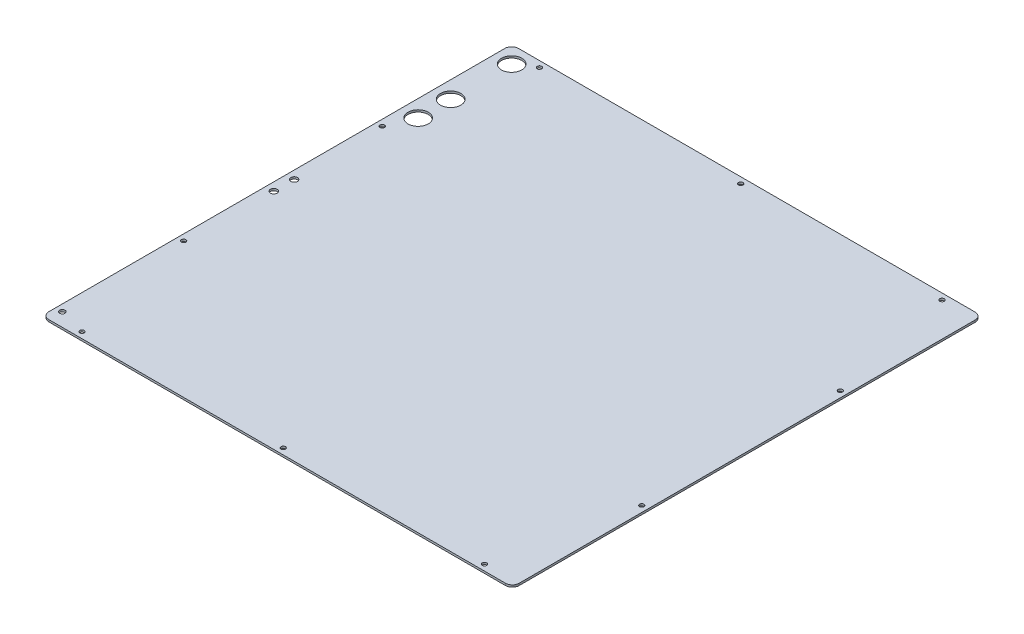
from build123d import *

# Parameters (mm, degrees)
SKETCH1_W            = 694
SKETCH1_H            = 693
BOSS_EXTRUDE1_DEPTH  = 3
M6_CLEARANCE_HOLE1_D = 6.6
LPATTERN1_COUNT      = 3
LPATTERN1_PITCH      = 297
MIRROR1_COPY_1_D     = 6.6
MIRROR1_COPY_2_D     = 6.6
M6_CLEARANCE_HOLE2_D = 6.6
LPATTERN2_COUNT      = 2
LPATTERN2_PITCH      = 293
MIRROR2_COPY_1_D     = 6.6
FILLET1_R            = 10
SKETCH6_R            = 4
SKETCH6_R_2          = 5
SKETCH6_R_3          = 15
CUT_EXTRUDE1_DEPTH   = 4


with BuildPart() as part:
    # Sketch1 → Boss-Extrude1 (new body)
    with BuildSketch(Plane(origin=(0, 0, 0), x_dir=(1, 0, 0), z_dir=(0, 1, 0))):
        Rectangle(SKETCH1_W, SKETCH1_H)
    extrude(amount=BOSS_EXTRUDE1_DEPTH)

    # M6 Clearance Hole1 (through all)
    with Locations(Plane(origin=(0, 3, 0), x_dir=(1, 0, 0), z_dir=(0, 1, 0))):
        with Locations((297, -337.5)):
            m6_clearance_hole1 = Hole(M6_CLEARANCE_HOLE1_D / 2)

    # LPattern1: M6 Clearance Hole1 ×3
    with Locations(*[(-i * LPATTERN1_PITCH, 0, 0) for i in range(1, LPATTERN1_COUNT)]):
        add(m6_clearance_hole1, mode=Mode.SUBTRACT)

    # Mirror1: M6 Clearance Hole1 across plane
    add(m6_clearance_hole1.mirror(Plane.XY), mode=Mode.SUBTRACT)

    # Mirror1 copy 1 (through all)
    with Locations(Plane(origin=(-297, 3, 0), x_dir=(1, 0, 0), z_dir=(0, 1, 0))):
        with Locations((297, 337.5)):
            Hole(MIRROR1_COPY_1_D / 2)

    # Mirror1 copy 2 (through all)
    with Locations(Plane(origin=(-594, 3, 0), x_dir=(1, 0, 0), z_dir=(0, 1, 0))):
        with Locations((297, 337.5)):
            Hole(MIRROR1_COPY_2_D / 2)

    # M6 Clearance Hole2 (through all)
    with Locations(Plane(origin=(0, 3, 0), x_dir=(1, 0, 0), z_dir=(0, 1, 0))):
        with Locations((338, -146.5)):
            m6_clearance_hole2 = Hole(M6_CLEARANCE_HOLE2_D / 2)

    # LPattern2: M6 Clearance Hole2 ×2
    with Locations(*[(0, 0, -i * LPATTERN2_PITCH) for i in range(1, LPATTERN2_COUNT)]):
        add(m6_clearance_hole2, mode=Mode.SUBTRACT)

    # Mirror2: M6 Clearance Hole2 across plane
    add(m6_clearance_hole2.mirror(Plane(origin=(0, 0, 0), x_dir=(0, 0, 1), z_dir=(1, 0, 0))), mode=Mode.SUBTRACT)

    # Mirror2 copy 1 (through all)
    with Locations(Plane(origin=(0, 3, -293), x_dir=(-1, 0, 0), z_dir=(0, 1, 0))):
        with Locations((338, 146.5)):
            Hole(MIRROR2_COPY_1_D / 2)

    # Fillet1
    fillet1_edges = [part.edges().sort_by_distance(p)[0] for p in [
        (-347, 1.5, -346.5),
        (347, 1.5, -346.5),
        (347, 1.5, 346.5),
        (-347, 1.5, 346.5),
    ]]
    fillet(fillet1_edges, radius=FILLET1_R)

    # Sketch6 → Cut-Extrude1 (cut, through all)
    with BuildSketch(Plane(origin=(0, 3, 0), x_dir=(1, 0, 0), z_dir=(0, 1, 0))):
        with Locations((-337, -326.5)):
            Circle(SKETCH6_R)
        with Locations((-335, -16.5)):
            Circle(SKETCH6_R_2)
        with Locations((-335, 13.5)):
            Circle(SKETCH6_R_2)
        with Locations((-322, 183.5)):
            Circle(SKETCH6_R_3)
        with Locations((-322, 231.5)):
            Circle(SKETCH6_R_3)
        with Locations((-322, 321.5)):
            Circle(SKETCH6_R_3)
    extrude(amount=-CUT_EXTRUDE1_DEPTH, mode=Mode.SUBTRACT)


solid = part.part
